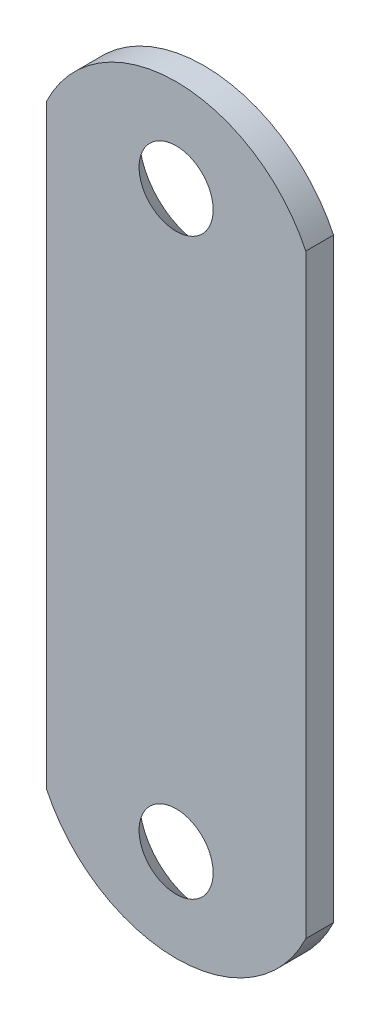
from build123d import *

# Parameters (mm, degrees)
EXTRUDE1_DEPTH = 1.5


with BuildPart() as part:
    # Sketch1 → Extrude1 (new body)
    with BuildSketch(Plane.XY):
        with BuildLine():
            Line((-7, 16.076033674), (-7, -16.076033674))
            ThreePointArc((-7, -16.076033674), (0, -20.5), (7, -16.076033674))
            Line((7, -16.076033674), (7, 16.076033674))
            ThreePointArc((7, 16.076033674), (0, 20.5), (-7, 16.076033674))
        make_face()
    extrude(amount=EXTRUDE1_DEPTH)

    # Sketch2 → Cut-Revolve2 (revolve, cut)
    with BuildSketch(Plane(origin=(0, 0, 0), x_dir=(0, 0, -1), z_dir=(1, 0, 0)), mode=Mode.PRIVATE) as cut_revolve2_sk:
        Polygon((0, -15.5), (0, -12), (-1.5, -13.5), (-1.5, -15.5), align=None)
    cut_revolve2 = revolve(cut_revolve2_sk.sketch.rotate(Axis((0, -15.5, 16.959144712), (0, 0, -1)), 90), axis=Axis((0, -15.5, 16.959144712), (0, 0, -1)), mode=Mode.SUBTRACT)  # turned: the seam where the file's is

    # Mirror1: Cut-Revolve2 across plane
    add(cut_revolve2.mirror(Plane.ZX), mode=Mode.SUBTRACT)


solid = part.part
